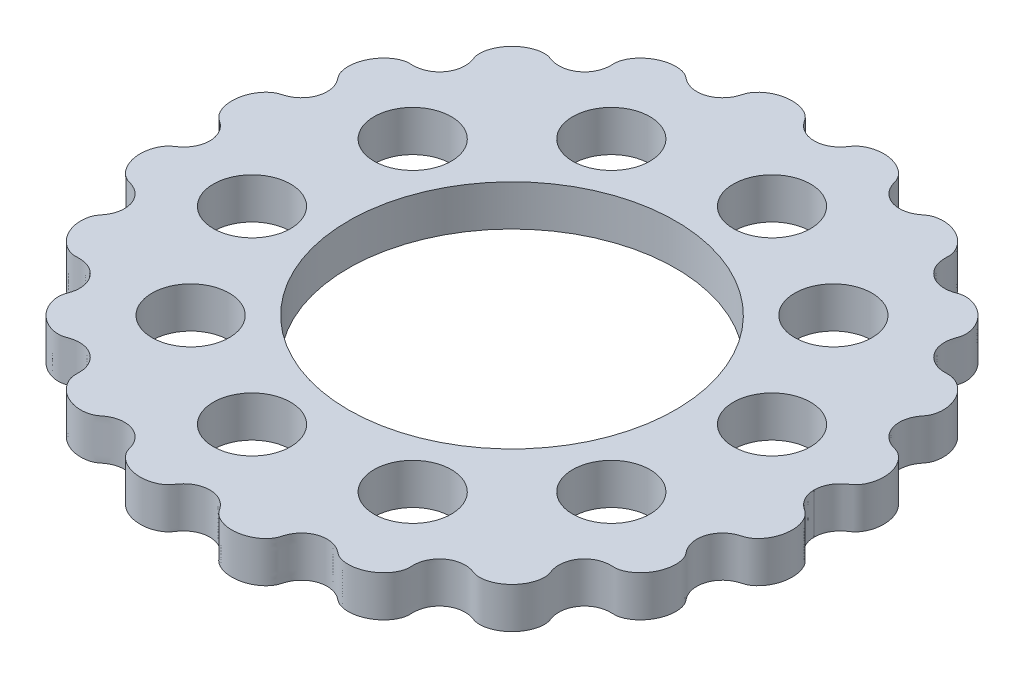
from build123d import *

# Parameters (mm, degrees)
SKETCH1_R           = 36
SKETCH1_R_2         = 8.5
BOSS_EXTRUDE1_DEPTH = 9


with BuildPart() as part:
    # Sketch1 → Boss-Extrude1 (new body)
    with BuildSketch(Plane(origin=(0, 0, 0), x_dir=(1, 0, 0), z_dir=(0, 1, 0))):
        with BuildLine():
            add(Edge.make_bspline(
                [(66.500001128, 0), (66.500001059, -0.306411594), (66.541874968, -0.881988953), (66.717851493, -1.709701791), (67.122305387, -2.644851491), (67.601319232, -3.385898949), (68.073478893, -3.930767458), (68.484626922, -4.318373679), (68.876385973, -4.631660736), (69.23366605, -4.885778545), (69.564274066, -5.103618626), (69.843214442, -5.321468249), (70.117872248, -5.581732182), (70.400827865, -5.901729423), (70.702289772, -6.323822122), (71.054596032, -6.952661705), (71.375662813, -7.747169256), (71.615376494, -8.685667315), (71.731212346, -9.758967782), (71.701410517, -10.823240749), (71.536133005, -11.860141317), (71.244225803, -12.853472484), (70.833511923, -13.788305153), (70.358839297, -14.565701482), (69.860707099, -15.191592971), (69.385303472, -15.666160963), (68.964677628, -16.012242354), (68.54812455, -16.287014566), (68.188697638, -16.47184613), (67.885284262, -16.589473761), (67.602667399, -16.678972646), (67.317739075, -16.760519914), (66.914744906, -16.885104227), (66.402737121, -17.079943872), (65.770956104, -17.391405147), (65.047003924, -17.880225418), (64.353873131, -18.53326648), (63.737773444, -19.372683578), (63.275037832, -20.335343335), (63.0008377, -21.369915642), (62.928927043, -22.453502643), (63.052813162, -23.427940228), (63.29775786, -24.251137277), (63.587039055, -24.893246727), (63.860894635, -25.371811065), (64.14516177, -25.790016356), (64.42550655, -26.153724672), (64.719695702, -26.532707758), (64.965405482, -26.968707858), (65.164480889, -27.455245241), (65.31533737, -27.986150481), (65.436916583, -28.660703569), (65.486679125, -29.479710927), (65.421096199, -30.426005629), (65.195898517, -31.477846243), (64.833514293, -32.483615902), (64.34589296, -33.427772819), (63.743613209, -34.295517302), (63.036397549, -35.071911937), (62.31941612, -35.667562121), (61.632614435, -36.102896741), (61.018606486, -36.397527132), (60.501368954, -36.585067293), (60.002736897, -36.705605448), (59.58278299, -36.754609085), (59.238659913, -36.755179392), (58.919479064, -36.74545807), (58.600187887, -36.737961797), (58.186622972, -36.744933287), (57.680555247, -36.788795106), (57.025772754, -36.90342477), (56.231100186, -37.148620439), (55.380154609, -37.568193838), (54.524775543, -38.212860553), (53.798856726, -39.016244646), (53.245744287, -39.931413305), (52.876403423, -40.932154503), (52.712876932, -41.903813394), (52.71112643, -42.801048319), (52.815319506, -43.527425087), (52.941387717, -44.033154822), (53.055590071, -44.395960767), (53.149312538, -44.668429528), (53.247939564, -44.939017738), (53.364965434, -45.291387687), (53.45219241, -45.737703326), (53.491958947, -46.257673261), (53.468644885, -46.845886586), (53.363394794, -47.556426715), (53.136734844, -48.374484468), (52.768362446, -49.246519445), (52.234936331, -50.143673448), (51.583820612, -50.970470144), (50.82500674, -51.71255133), (49.978560671, -52.346849839), (49.058219135, -52.860671903), (48.20083524, -53.193586938), (47.439728454, -53.383993294), (46.783575504, -53.471154388), (46.243400169, -53.490536958), (45.735563963, -53.453013122), (45.317452544, -53.369908656), (44.991727079, -53.265499676), (44.699608392, -53.161002685), (44.407046102, -53.057647907), (44.006263136, -52.932952751), (43.490986385, -52.811450458), (42.800133998, -52.714477579), (41.927158987, -52.709986791), (40.953037618, -52.867456762), (39.920202856, -53.248888969), (38.974122336, -53.827688375), (38.169054016, -54.570301655), (37.529920824, -55.442926734), (37.10189733, -56.344011558), (36.879347753, -57.124787428), (36.78026494, -57.75948784), (36.74543056, -58.228868163), (36.738116128, -58.595650919), (36.745630265, -58.954274122), (36.758794674, -59.304761395), (36.74528446, -59.700076552), (36.677901941, -60.135221885), (36.549281487, -60.614594775), (36.349127336, -61.129714817), (36.04054693, -61.740807428), (35.589726473, -62.423279244), (34.976854854, -63.134572488), (34.181164503, -63.833500064), (33.295605945, -64.424159898), (32.335438572, -64.896819576), (31.315952581, -65.240823473), (30.253281676, -65.444073244), (29.302808185, -65.486744282), (28.486094508, -65.414976344), (27.817189287, -65.273610717), (27.358637794, -65.126885219), (26.982811323, -64.964513335), (26.641526331, -64.7794663), (26.38252315, -64.604446296), (26.143451517, -64.417035727), (25.861696042, -64.202004354), (25.573543831, -63.995425393), (25.213648928, -63.766134462), (24.77357167, -63.531438351), (24.173339527, -63.273837977), (23.390590515, -63.045984286), (22.436442541, -62.9272463), (21.334482976, -63.005704166), (20.269322456, -63.297023223), (19.302800806, -63.777682853), (18.465112618, -64.415546123), (17.821174318, -65.123747711), (17.348875456, -65.844632989), (17.049246652, -66.473739286), (16.87955898, -66.936238427), (16.773116623, -67.27871396), (16.696957562, -67.537958364), (16.620563074, -67.797132006), (16.499910107, -68.130001521), (16.302573623, -68.520910326), (16.023587778, -68.951670557), (15.649895083, -69.406906758), (15.139193985, -69.909948046), (14.469235427, -70.425872158), (13.660692235, -70.898780651), (12.712675609, -71.294352148), (11.701994626, -71.570793248), (10.643277717, -71.717442021), (9.574432128, -71.722251809), (8.515173692, -71.581185143), (7.619740366, -71.330051456), (6.891782338, -71.021756352), (6.368073295, -70.723825795), (6.025748963, -70.488703324), (5.756441978, -70.272176079), (5.552614161, -70.086041745), (5.329274804, -69.853141567), (5.101427256, -69.562377498), (4.873847854, -69.214977549), (4.60464153, -68.839770094), (4.294594159, -68.458351882), (3.934688297, -68.081320026), (3.4174137, -67.628524208), (2.704193701, -67.152903461), (1.792081682, -66.743306019), (0.685094475, -66.494130595), (-0.466681251, -66.470382136), (-1.460634006, -66.655247728), (-2.272771141, -66.955831296), (-2.910711395, -67.297398997), (-3.378756398, -67.611091869), (-3.798269807, -67.955365828), (-4.170377952, -68.321327121), (-4.46025194, -68.657656792), (-4.682293422, -68.948557771), (-4.858086872, -69.197625908), (-4.995153001, -69.399303863), (-5.139637336, -69.607565652), (-5.30066338, -69.815692291), (-5.483879702, -70.017863174), (-5.688139816, -70.212714263), (-5.959120705, -70.439264474), (-6.305281109, -70.684848155), (-6.832662082, -70.993284834), (-7.564845294, -71.311344159), (-8.469002263, -71.572281829), (-9.541810964, -71.721249229), (-10.62436062, -71.719760269), (-11.695875611, -71.572466315), (-12.712675441, -71.294352571), (-13.660692303, -70.898780375), (-14.46923534, -70.425872341), (-15.139193993, -69.909947949), (-15.649895037, -69.40690682), (-16.023587763, -68.95167053), (-16.302573589, -68.520910355), (-16.499910085, -68.130001517), (-16.620563046, -67.797132021), (-16.696957538, -67.537958369), (-16.773116596, -67.278713971), (-16.879558957, -66.936238431), (-17.049246621, -66.473739301), (-17.348875437, -65.844632989), (-17.821174285, -65.123747732), (-18.465112607, -64.415546115), (-19.302800763, -63.777682889), (-20.269322463, -63.297023191), (-21.334482901, -63.005704246), (-22.436442607, -62.927246188), (-23.390590346, -63.045984495), (-24.17333974, -63.273837665), (-24.773571206, -63.531438965), (-25.213650233, -63.76613266), (-25.573539136, -63.995431782), (-25.861714806, -64.201978716), (-26.096423256, -64.381291369), (-26.283123055, -64.526166107), (-26.480463985, -64.670880418), (-26.693581001, -64.807563754), (-26.982772329, -64.964566552), (-27.358660612, -65.126854047), (-27.817177554, -65.273626716), (-28.486102111, -65.414965944), (-29.302803074, -65.48675124), (-30.253284842, -65.444068902), (-31.315950722, -65.240825994), (-32.335439647, -64.896818091), (-33.295605247, -64.424160835), (-34.181164906, -63.833499498), (-34.976854539, -63.134572903), (-35.589726623, -62.423279025), (-36.040546819, -61.740807566), (-36.349127362, -61.129714768), (-36.54928143, -60.61459484), (-36.67790194, -60.135221874), (-36.745284426, -59.700076587), (-36.758794659, -59.304761404), (-36.745630238, -58.954274147), (-36.738116109, -58.595650934), (-36.745430538, -58.228868183), (-36.78026492, -57.759487858), (-36.879347732, -57.124787447), (-37.10189731, -56.344011576), (-37.529920804, -55.442926753), (-38.169053997, -54.570301674), (-38.974122317, -53.827688394), (-39.920202837, -53.248888989), (-40.953037599, -52.867456782), (-41.927158969, -52.709986812), (-42.800133979, -52.7144776), (-43.490986366, -52.811450479), (-44.006263117, -52.932952773), (-44.407046083, -53.057647929), (-44.699608373, -53.161002708), (-44.99172706, -53.265499699), (-45.317452525, -53.369908679), (-45.735563943, -53.453013145), (-46.24340015, -53.49053698), (-46.783575485, -53.471154412), (-47.439728436, -53.383993317), (-48.200835218, -53.193586964), (-49.05821912, -52.860671924), (-49.978560646, -52.346849869), (-50.825006732, -51.712551347), (-51.58382058, -50.970470183), (-52.234936338, -50.143673452), (-52.768362387, -49.246519509), (-53.136734895, -48.374484434), (-53.363394674, -47.556426834), (-53.468645012, -46.845886486), (-53.491958675, -46.257673515), (-53.452192823, -45.737702973), (-53.364964725, -45.291388329), (-53.247940119, -44.939017259), (-53.149315767, -44.668426679), (-53.055570757, -44.395977907), (-52.969692355, -44.122896909), (-52.883657784, -43.80178229), (-52.788277591, -43.338670556), (-52.711291111, -42.706581427), (-52.712889666, -41.903802117), (-52.876396004, -40.932161097), (-53.24574868, -39.931409425), (-53.798854055, -39.01624703), (-54.524777209, -38.212859093), (-55.380153425, -37.568194906), (-56.231100936, -37.148619792), (-57.025772272, -36.903425216), (-57.680555542, -36.788794863), (-58.186622745, -36.744933508), (-58.600187986, -36.737961729), (-58.919479016, -36.745458132), (-59.238659916, -36.755179409), (-59.582782972, -36.754609121), (-60.002736891, -36.705605474), (-60.501368941, -36.585067325), (-61.018606477, -36.397527162), (-61.632614424, -36.102896772), (-62.319416111, -35.667562152), (-63.036397538, -35.071911969), (-63.7436132, -34.295517334), (-64.345892951, -33.427772851), (-64.833514284, -32.483615934), (-65.195898509, -31.477846275), (-65.421096192, -30.426005662), (-65.486679118, -29.47971096), (-65.436916577, -28.660703602), (-65.315337364, -27.986150513), (-65.164480883, -27.455245273), (-64.965405476, -26.968707891), (-64.719695696, -26.53270779), (-64.425506545, -26.153724704), (-64.145161765, -25.790016388), (-63.86089463, -25.371811097), (-63.58703905, -24.893246759), (-63.297757856, -24.251137308), (-63.052813158, -23.42794026), (-62.92892704, -22.453502674), (-63.000837697, -21.369915674), (-63.275037829, -20.335343367), (-63.737773443, -19.372683609), (-64.353873129, -18.533266513), (-65.047003923, -17.88022545), (-65.770956103, -17.39140518), (-66.40273712, -17.079943905), (-66.914744905, -16.885104261), (-67.317739074, -16.760519947), (-67.602667399, -16.67897268), (-67.885284262, -16.589473795), (-68.188697637, -16.471846164), (-68.548124549, -16.287014601), (-68.964677628, -16.012242388), (-69.385303472, -15.666160998), (-69.860707099, -15.191593006), (-70.358839297, -14.565701517), (-70.833511923, -13.788305189), (-71.244225804, -12.85347252), (-71.536133007, -11.860141352), (-71.701410519, -10.823240785), (-71.731212348, -9.758967818), (-71.615376497, -8.685667351), (-71.375662817, -7.747169291), (-71.054596036, -6.952661741), (-70.702289777, -6.323822157), (-70.40082787, -5.901729458), (-70.117872253, -5.581732217), (-69.843214447, -5.321468285), (-69.564274071, -5.103618659), (-69.233666057, -4.885778583), (-68.876385976, -4.631660764), (-68.484626931, -4.318373725), (-68.073478892, -3.930767473), (-67.601319247, -3.38589901), (-67.122305379, -2.644851485), (-66.717851516, -1.709701875), (-66.541874949, -0.881988899), (-66.500001067, -0.306411595), (-66.500001144, 0)],
                knots=[0.107227573, 0.107227573, 0.107227573, 0.107227573, 0.107227573, 0.110899605, 0.114125262, 0.117297955, 0.119365342, 0.12143273, 0.122745926, 0.124059122, 0.125372319, 0.126685515, 0.127489642, 0.128293769, 0.129902022, 0.131796763, 0.133691503, 0.136915486, 0.14013947, 0.143363023, 0.146586577, 0.149636972, 0.152687367, 0.155737512, 0.158787658, 0.160518035, 0.162248411, 0.16377611, 0.165303808, 0.166487656, 0.16707958, 0.167671505, 0.168855353, 0.170039201, 0.172133935, 0.174228668, 0.177277837, 0.180469506, 0.183482711, 0.186636923, 0.190006747, 0.193215352, 0.196415061, 0.198338344, 0.200261626, 0.201638223, 0.203014821, 0.204391418, 0.205768015, 0.20737848, 0.208988945, 0.210678965, 0.212368986, 0.215581346, 0.218793706, 0.222006092, 0.225218479, 0.228355258, 0.231492038, 0.234628768, 0.237765499, 0.239487542, 0.241209585, 0.242778062, 0.244346538, 0.245622308, 0.246260192, 0.246898077, 0.248173846, 0.249449616, 0.251214165, 0.252978714, 0.256127597, 0.259382101, 0.262517266, 0.265738303, 0.269026705, 0.272116988, 0.275225209, 0.2774808, 0.279736391, 0.280887314, 0.281462776, 0.282038237, 0.28318916, 0.284340084, 0.285905879, 0.287471675, 0.289425665, 0.291379655, 0.294497435, 0.297615215, 0.300732841, 0.303850467, 0.307074425, 0.310298382, 0.31337072, 0.316443057, 0.318059604, 0.319676151, 0.321292619, 0.322909086, 0.324148554, 0.324768288, 0.325388022, 0.32662749, 0.327866958, 0.329795802, 0.331724645, 0.334971979, 0.338289395, 0.341547885, 0.344835886, 0.34817973, 0.35133024, 0.354430803, 0.35672383, 0.357870343, 0.359016857, 0.360067543, 0.361118229, 0.362168914, 0.3632196, 0.364800497, 0.366381395, 0.368105721, 0.369830048, 0.372993142, 0.376156236, 0.379319389, 0.382482541, 0.385713434, 0.388944326, 0.392175014, 0.395405702, 0.397072955, 0.398740208, 0.400355996, 0.401163891, 0.401971785, 0.403387693, 0.404095647, 0.404803601, 0.40621951, 0.407635418, 0.409204663, 0.410773909, 0.414037141, 0.417372109, 0.420655125, 0.423928266, 0.427187498, 0.430226971, 0.433200462, 0.435339705, 0.437478948, 0.43855829, 0.43909796, 0.439637631, 0.440716972, 0.441796314, 0.443334185, 0.444872057, 0.446855976, 0.448839896, 0.451908577, 0.454977259, 0.45804593, 0.461114601, 0.464431853, 0.467749105, 0.470814309, 0.473879513, 0.475538589, 0.477197664, 0.478024147, 0.47885063, 0.479677113, 0.480503596, 0.481886651, 0.483269706, 0.48465276, 0.486035815, 0.487772004, 0.489508194, 0.492878492, 0.496270276, 0.499675403, 0.503014057, 0.506592321, 0.50830093, 0.51000954, 0.51167164, 0.513333741, 0.51479501, 0.51625628, 0.516986914, 0.517717549, 0.518448184, 0.519178819, 0.520023889, 0.52086896, 0.52171403, 0.522559101, 0.524253928, 0.525948755, 0.529023994, 0.532099233, 0.535492308, 0.538885383, 0.541954054, 0.545022725, 0.548091406, 0.551160088, 0.553144007, 0.555127927, 0.556665798, 0.55820367, 0.559283011, 0.560362353, 0.560902023, 0.561441694, 0.562521035, 0.564660278, 0.566799521, 0.569773013, 0.572812485, 0.576071718, 0.579344859, 0.582627875, 0.585962843, 0.589226075, 0.59079532, 0.592364566, 0.593780474, 0.595196382, 0.595904336, 0.59661229, 0.597320244, 0.598028198, 0.598836093, 0.599643987, 0.601259776, 0.602927029, 0.604594282, 0.60782497, 0.611055658, 0.61428655, 0.617517442, 0.620680595, 0.623843748, 0.627006842, 0.630169936, 0.631894262, 0.633618589, 0.635199486, 0.636780383, 0.637831069, 0.638881755, 0.639932441, 0.640983127, 0.64212964, 0.643276154, 0.645569181, 0.648669744, 0.651820253, 0.655164097, 0.658452098, 0.661710588, 0.665028004, 0.668275338, 0.670204182, 0.672133025, 0.673372493, 0.674611961, 0.675231696, 0.67585143, 0.677090898, 0.678707365, 0.680323832, 0.681940379, 0.683556927, 0.686629264, 0.689701601, 0.692925559, 0.696149516, 0.699267143, 0.702384769, 0.705502549, 0.708620329, 0.710574319, 0.712528308, 0.714094104, 0.7156599, 0.716810823, 0.717961746, 0.718537208, 0.719112669, 0.720263592, 0.721391388, 0.722519183, 0.724774775, 0.727882996, 0.730973278, 0.734261681, 0.737482718, 0.740617883, 0.743872386, 0.747021269, 0.748785818, 0.750550368, 0.751826137, 0.753101906, 0.753739791, 0.754377676, 0.755653445, 0.757221922, 0.758790398, 0.760512441, 0.762234484, 0.765371215, 0.768507946, 0.771644725, 0.774781505, 0.777993891, 0.781206278, 0.784418638, 0.787630998, 0.789321018, 0.791011039, 0.792621503, 0.794231968, 0.795608565, 0.796985163, 0.79836176, 0.799738358, 0.80166164, 0.803584922, 0.806784631, 0.809993236, 0.81336306, 0.816517272, 0.819530478, 0.822722147, 0.825771315, 0.827866049, 0.829960782, 0.831144631, 0.832328479, 0.832920403, 0.833512327, 0.834696176, 0.836223874, 0.837751572, 0.839481949, 0.841212326, 0.844262471, 0.847312617, 0.850363012, 0.853413407, 0.85663696, 0.859860514, 0.863084497, 0.866308481, 0.868203221, 0.870097961, 0.871706215, 0.872510342, 0.873314469, 0.874627665, 0.875940861, 0.877254057, 0.878567254, 0.880634641, 0.882702029, 0.885874721, 0.889100378, 0.892772411, 0.892772411, 0.892772411, 0.892772411, 0.892772411], degree=4))
            add(Edge.make_bspline(
                [(66.500001128, 0), (66.500001048, 0.306411644), (66.541874947, 0.881989055), (66.717851473, 1.709701945), (67.122305387, 2.644851692), (67.601319232, 3.38589915), (68.073478893, 3.930767659), (68.484626922, 4.318373879), (68.876385973, 4.631660937), (69.23366605, 4.885778745), (69.564274066, 5.103618826), (69.843214442, 5.32146845), (70.117872248, 5.581732383), (70.400827865, 5.901729623), (70.702289772, 6.323822322), (71.054596032, 6.952661906), (71.375662813, 7.747169456), (71.615376494, 8.685667516), (71.731212346, 9.758967983), (71.701410517, 10.82324095), (71.536133005, 11.860141517), (71.244225803, 12.853472685), (70.833511923, 13.788305354), (70.358839297, 14.565701682), (69.860707099, 15.191593171), (69.385303472, 15.666161164), (68.964677628, 16.012242554), (68.54812455, 16.287014767), (68.188697638, 16.471846331), (67.885284262, 16.589473962), (67.602667399, 16.678972847), (67.317739075, 16.760520114), (66.914744906, 16.885104428), (66.402737121, 17.079944072), (65.770956104, 17.391405347), (65.047003924, 17.880225618), (64.353873131, 18.533266681), (63.737773444, 19.372683778), (63.275037832, 20.335343536), (63.0008377, 21.369915843), (62.928927043, 22.453502843), (63.052813162, 23.427940429), (63.29775786, 24.251137477), (63.587039055, 24.893246928), (63.860894635, 25.371811266), (64.14516177, 25.790016557), (64.42550655, 26.153724872), (64.719695702, 26.532707958), (64.965405482, 26.968708059), (65.164480889, 27.455245441), (65.31533737, 27.986150681), (65.436916583, 28.66070377), (65.486679125, 29.479711128), (65.421096199, 30.426005829), (65.195898517, 31.477846443), (64.833514293, 32.483616102), (64.34589296, 33.427773019), (63.743613209, 34.295517502), (63.036397549, 35.071912137), (62.31941612, 35.667562321), (61.632614435, 36.102896941), (61.018606486, 36.397527333), (60.501368954, 36.585067493), (60.002736897, 36.705605648), (59.58278299, 36.754609285), (59.238659913, 36.755179592), (58.919479064, 36.745458271), (58.600187886, 36.737961997), (58.186622972, 36.744933488), (57.680555247, 36.788795306), (57.025772753, 36.90342497), (56.231100186, 37.148620639), (55.380154609, 37.568194039), (54.524775543, 38.212860754), (53.798856726, 39.016244846), (53.245744287, 39.931413505), (52.876403423, 40.932154703), (52.712876932, 41.903813594), (52.71112643, 42.80104852), (52.815319506, 43.527425287), (52.941387717, 44.033155022), (53.055590071, 44.395960967), (53.149312538, 44.668429729), (53.247939564, 44.939017938), (53.364965434, 45.291387887), (53.45219241, 45.737703526), (53.491958947, 46.257673461), (53.468644885, 46.845886786), (53.363394794, 47.556426915), (53.136734844, 48.374484668), (52.768362446, 49.246519645), (52.234936331, 50.143673648), (51.583820612, 50.970470345), (50.82500674, 51.71255153), (49.978560671, 52.34685004), (49.058219135, 52.860672104), (48.20083524, 53.193587139), (47.439728454, 53.383993495), (46.783575504, 53.471154589), (46.243400169, 53.490537158), (45.735563962, 53.453013323), (45.317452544, 53.369908857), (44.991727079, 53.265499877), (44.699608392, 53.161002886), (44.407046102, 53.057648107), (44.006263136, 52.932952951), (43.490986385, 52.811450658), (42.800133998, 52.714477779), (41.927158987, 52.709986991), (40.953037618, 52.867456962), (39.920202856, 53.248889169), (38.974122336, 53.827688575), (38.169054016, 54.570301855), (37.529920824, 55.442926934), (37.10189733, 56.344011758), (36.879347753, 57.124787628), (36.78026494, 57.75948804), (36.74543056, 58.228868364), (36.738116128, 58.595651119), (36.745630265, 58.954274323), (36.758794674, 59.304761595), (36.74528446, 59.700076752), (36.677901941, 60.135222085), (36.549281487, 60.614594976), (36.349127336, 61.129715017), (36.04054693, 61.740807628), (35.589726472, 62.423279444), (34.976854854, 63.134572689), (34.181164503, 63.833500264), (33.295605945, 64.424160099), (32.335438572, 64.896819776), (31.315952581, 65.240823674), (30.253281676, 65.444073444), (29.302808185, 65.486744482), (28.486094508, 65.414976544), (27.817189287, 65.273610917), (27.358637794, 65.12688542), (26.982811323, 64.964513535), (26.641526331, 64.7794665), (26.38252315, 64.604446497), (26.143451517, 64.417035928), (25.861696042, 64.202004554), (25.573543831, 63.995425594), (25.213648928, 63.766134662), (24.77357167, 63.531438552), (24.173339527, 63.273838177), (23.390590515, 63.045984486), (22.436442541, 62.927246501), (21.334482976, 63.005704366), (20.269322456, 63.297023423), (19.302800806, 63.777683053), (18.465112618, 64.415546323), (17.821174318, 65.123747912), (17.348875456, 65.844633189), (17.049246652, 66.473739486), (16.87955898, 66.936238627), (16.773116623, 67.278714161), (16.696957562, 67.537958564), (16.620563074, 67.797132207), (16.499910107, 68.130001722), (16.302573623, 68.520910526), (16.023587778, 68.951670757), (15.649895083, 69.406906958), (15.139193984, 69.909948246), (14.469235427, 70.425872358), (13.660692235, 70.898780851), (12.712675609, 71.294352349), (11.701994626, 71.570793448), (10.643277717, 71.717442222), (9.574432128, 71.72225201), (8.515173692, 71.581185343), (7.619740366, 71.330051656), (6.891782338, 71.021756552), (6.368073295, 70.723825995), (6.025748963, 70.488703524), (5.756441978, 70.27217628), (5.552614161, 70.086041945), (5.329274804, 69.853141768), (5.101427256, 69.562377698), (4.873847854, 69.21497775), (4.60464153, 68.839770294), (4.294594159, 68.458352082), (3.934688297, 68.081320226), (3.4174137, 67.628524408), (2.704193701, 67.152903662), (1.792081682, 66.74330622), (0.685094475, 66.494130795), (-0.466681251, 66.470382336), (-1.460634006, 66.655247928), (-2.272771141, 66.955831497), (-2.910711395, 67.297399197), (-3.378756398, 67.61109207), (-3.798269807, 67.955366028), (-4.170377952, 68.321327321), (-4.46025194, 68.657656993), (-4.682293422, 68.948557972), (-4.858086872, 69.197626109), (-4.995153001, 69.399304063), (-5.139637336, 69.607565852), (-5.30066338, 69.815692491), (-5.483879702, 70.017863374), (-5.688139816, 70.212714464), (-5.959120705, 70.439264675), (-6.305281109, 70.684848355), (-6.832662082, 70.993285034), (-7.564845294, 71.311344359), (-8.469002263, 71.57228203), (-9.541810964, 71.721249429), (-10.624360621, 71.71976047), (-11.695875611, 71.572466515), (-12.712675441, 71.294352771), (-13.660692303, 70.898780575), (-14.46923534, 70.425872542), (-15.139193993, 69.90994815), (-15.649895037, 69.40690702), (-16.023587763, 68.951670731), (-16.302573589, 68.520910555), (-16.499910085, 68.130001717), (-16.620563046, 67.797132221), (-16.696957538, 67.53795857), (-16.773116596, 67.278714171), (-16.879558957, 66.936238632), (-17.049246621, 66.473739501), (-17.348875437, 65.844633189), (-17.821174285, 65.123747932), (-18.465112607, 64.415546315), (-19.302800763, 63.777683089), (-20.269322463, 63.297023391), (-21.334482901, 63.005704446), (-22.436442607, 62.927246389), (-23.390590347, 63.045984695), (-24.17333974, 63.273837865), (-24.773571206, 63.531439165), (-25.213650233, 63.76613286), (-25.573539137, 63.995431983), (-25.861714806, 64.201978916), (-26.096423256, 64.38129157), (-26.283123055, 64.526166307), (-26.480463985, 64.670880618), (-26.693581001, 64.807563954), (-26.982772329, 64.964566752), (-27.358660612, 65.126854247), (-27.817177554, 65.273626916), (-28.486102111, 65.414966144), (-29.302803074, 65.486751441), (-30.253284842, 65.444069102), (-31.315950722, 65.240826194), (-32.335439647, 64.896818292), (-33.295605247, 64.424161035), (-34.181164906, 63.833499699), (-34.976854539, 63.134573104), (-35.589726623, 62.423279225), (-36.040546819, 61.740807767), (-36.349127362, 61.129714968), (-36.54928143, 60.614595041), (-36.67790194, 60.135222074), (-36.745284426, 59.700076787), (-36.758794659, 59.304761604), (-36.745630238, 58.954274348), (-36.738116109, 58.595651134), (-36.745430538, 58.228868384), (-36.78026492, 57.759488058), (-36.879347732, 57.124787647), (-37.10189731, 56.344011776), (-37.529920804, 55.442926953), (-38.169053997, 54.570301874), (-38.974122317, 53.827688595), (-39.920202837, 53.248889189), (-40.953037599, 52.867456983), (-41.927158969, 52.709987012), (-42.800133979, 52.7144778), (-43.490986366, 52.81145068), (-44.006263117, 52.932952973), (-44.407046083, 53.057648129), (-44.699608373, 53.161002908), (-44.99172706, 53.265499899), (-45.317452525, 53.369908879), (-45.735563943, 53.453013346), (-46.24340015, 53.490537181), (-46.783575485, 53.471154612), (-47.439728436, 53.383993517), (-48.200835218, 53.193587165), (-49.05821912, 52.860672125), (-49.978560646, 52.34685007), (-50.825006732, 51.712551548), (-51.58382058, 50.970470383), (-52.234936338, 50.143673653), (-52.768362387, 49.246519709), (-53.136734895, 48.374484635), (-53.363394674, 47.556427034), (-53.468645012, 46.845886686), (-53.491958675, 46.257673715), (-53.452192823, 45.737703173), (-53.364964725, 45.29138853), (-53.247940119, 44.93901746), (-53.149315767, 44.668426879), (-53.055570757, 44.395978107), (-52.969692355, 44.122897109), (-52.883657784, 43.801782491), (-52.788277591, 43.338670756), (-52.711291111, 42.706581628), (-52.712889666, 41.903802317), (-52.876396004, 40.932161297), (-53.24574868, 39.931409626), (-53.798854055, 39.016247231), (-54.524777209, 38.212859293), (-55.380153425, 37.568195106), (-56.231100936, 37.148619992), (-57.025772272, 36.903425416), (-57.680555542, 36.788795064), (-58.186622745, 36.744933709), (-58.600187986, 36.737961929), (-58.919479016, 36.745458333), (-59.238659916, 36.75517961), (-59.582782972, 36.754609322), (-60.002736891, 36.705605674), (-60.501368941, 36.585067525), (-61.018606477, 36.397527362), (-61.632614424, 36.102896972), (-62.319416111, 35.667562352), (-63.036397538, 35.071912169), (-63.7436132, 34.295517534), (-64.345892951, 33.427773051), (-64.833514284, 32.483616134), (-65.195898509, 31.477846476), (-65.421096192, 30.426005862), (-65.486679118, 29.47971116), (-65.436916577, 28.660703802), (-65.315337364, 27.986150714), (-65.164480883, 27.455245473), (-64.965405476, 26.968708091), (-64.719695696, 26.53270799), (-64.425506545, 26.153724904), (-64.145161765, 25.790016589), (-63.86089463, 25.371811297), (-63.58703905, 24.893246959), (-63.297757856, 24.251137509), (-63.052813158, 23.42794046), (-62.92892704, 22.453502875), (-63.000837697, 21.369915874), (-63.275037829, 20.335343567), (-63.737773443, 19.37268381), (-64.353873129, 18.533266713), (-65.047003923, 17.880225651), (-65.770956103, 17.39140538), (-66.40273712, 17.079944105), (-66.914744905, 16.885104461), (-67.317739074, 16.760520147), (-67.602667399, 16.67897288), (-67.885284262, 16.589473995), (-68.188697637, 16.471846364), (-68.548124549, 16.287014801), (-68.964677628, 16.012242588), (-69.385303472, 15.666161198), (-69.860707099, 15.191593206), (-70.358839297, 14.565701717), (-70.833511923, 13.788305389), (-71.244225804, 12.85347272), (-71.536133007, 11.860141553), (-71.701410519, 10.823240985), (-71.731212348, 9.758968018), (-71.615376497, 8.685667551), (-71.375662817, 7.747169491), (-71.054596036, 6.952661941), (-70.702289777, 6.323822357), (-70.40082787, 5.901729659), (-70.117872253, 5.581732417), (-69.843214447, 5.321468485), (-69.564274071, 5.103618859), (-69.233666057, 4.885778784), (-68.876385976, 4.631660964), (-68.484626931, 4.318373925), (-68.073478893, 3.930767674), (-67.601319247, 3.38589921), (-67.122305379, 2.644851686), (-66.717851496, 1.709702029), (-66.541874928, 0.881989001), (-66.500001056, 0.306411645), (-66.500001144, 0)],
                knots=[0.107227572, 0.107227572, 0.107227572, 0.107227572, 0.107227572, 0.110899605, 0.114125262, 0.117297955, 0.119365342, 0.12143273, 0.122745926, 0.124059122, 0.125372319, 0.126685515, 0.127489642, 0.128293769, 0.129902022, 0.131796763, 0.133691503, 0.136915486, 0.14013947, 0.143363023, 0.146586577, 0.149636972, 0.152687367, 0.155737512, 0.158787658, 0.160518035, 0.162248411, 0.16377611, 0.165303808, 0.166487656, 0.16707958, 0.167671505, 0.168855353, 0.170039201, 0.172133935, 0.174228668, 0.177277837, 0.180469506, 0.183482711, 0.186636923, 0.190006747, 0.193215352, 0.196415061, 0.198338344, 0.200261626, 0.201638223, 0.203014821, 0.204391418, 0.205768015, 0.20737848, 0.208988945, 0.210678965, 0.212368986, 0.215581346, 0.218793706, 0.222006092, 0.225218479, 0.228355258, 0.231492038, 0.234628768, 0.237765499, 0.239487542, 0.241209585, 0.242778062, 0.244346538, 0.245622308, 0.246260192, 0.246898077, 0.248173846, 0.249449616, 0.251214165, 0.252978714, 0.256127597, 0.259382101, 0.262517266, 0.265738303, 0.269026705, 0.272116988, 0.275225209, 0.2774808, 0.279736391, 0.280887314, 0.281462776, 0.282038237, 0.28318916, 0.284340084, 0.285905879, 0.287471675, 0.289425665, 0.291379655, 0.294497435, 0.297615215, 0.300732841, 0.303850467, 0.307074425, 0.310298382, 0.31337072, 0.316443057, 0.318059604, 0.319676151, 0.321292619, 0.322909086, 0.324148554, 0.324768288, 0.325388022, 0.32662749, 0.327866958, 0.329795802, 0.331724645, 0.334971979, 0.338289395, 0.341547885, 0.344835886, 0.34817973, 0.35133024, 0.354430803, 0.35672383, 0.357870343, 0.359016857, 0.360067543, 0.361118229, 0.362168914, 0.3632196, 0.364800497, 0.366381395, 0.368105721, 0.369830048, 0.372993142, 0.376156236, 0.379319389, 0.382482541, 0.385713434, 0.388944326, 0.392175014, 0.395405702, 0.397072955, 0.398740208, 0.400355996, 0.401163891, 0.401971785, 0.403387693, 0.404095647, 0.404803601, 0.40621951, 0.407635418, 0.409204663, 0.410773909, 0.414037141, 0.417372109, 0.420655125, 0.423928266, 0.427187498, 0.430226971, 0.433200462, 0.435339705, 0.437478948, 0.43855829, 0.43909796, 0.439637631, 0.440716972, 0.441796314, 0.443334185, 0.444872057, 0.446855976, 0.448839896, 0.451908577, 0.454977259, 0.45804593, 0.461114601, 0.464431853, 0.467749105, 0.470814309, 0.473879513, 0.475538589, 0.477197664, 0.478024147, 0.47885063, 0.479677113, 0.480503596, 0.481886651, 0.483269706, 0.48465276, 0.486035815, 0.487772004, 0.489508194, 0.492878492, 0.496270276, 0.499675403, 0.503014057, 0.506592321, 0.50830093, 0.51000954, 0.51167164, 0.513333741, 0.51479501, 0.51625628, 0.516986914, 0.517717549, 0.518448184, 0.519178819, 0.520023889, 0.52086896, 0.52171403, 0.522559101, 0.524253928, 0.525948755, 0.529023994, 0.532099233, 0.535492308, 0.538885383, 0.541954054, 0.545022725, 0.548091406, 0.551160088, 0.553144007, 0.555127927, 0.556665798, 0.55820367, 0.559283011, 0.560362353, 0.560902023, 0.561441694, 0.562521035, 0.564660278, 0.566799521, 0.569773013, 0.572812485, 0.576071718, 0.579344859, 0.582627875, 0.585962843, 0.589226075, 0.59079532, 0.592364566, 0.593780474, 0.595196382, 0.595904336, 0.59661229, 0.597320244, 0.598028198, 0.598836093, 0.599643987, 0.601259776, 0.602927029, 0.604594282, 0.60782497, 0.611055658, 0.61428655, 0.617517442, 0.620680595, 0.623843748, 0.627006842, 0.630169936, 0.631894262, 0.633618589, 0.635199486, 0.636780383, 0.637831069, 0.638881755, 0.639932441, 0.640983127, 0.64212964, 0.643276154, 0.645569181, 0.648669744, 0.651820253, 0.655164097, 0.658452098, 0.661710588, 0.665028004, 0.668275338, 0.670204182, 0.672133025, 0.673372493, 0.674611961, 0.675231696, 0.67585143, 0.677090898, 0.678707365, 0.680323832, 0.681940379, 0.683556927, 0.686629264, 0.689701601, 0.692925559, 0.696149516, 0.699267143, 0.702384769, 0.705502549, 0.708620329, 0.710574319, 0.712528308, 0.714094104, 0.7156599, 0.716810823, 0.717961746, 0.718537208, 0.719112669, 0.720263592, 0.721391388, 0.722519183, 0.724774775, 0.727882996, 0.730973278, 0.734261681, 0.737482718, 0.740617883, 0.743872386, 0.747021269, 0.748785818, 0.750550368, 0.751826137, 0.753101906, 0.753739791, 0.754377676, 0.755653445, 0.757221922, 0.758790398, 0.760512441, 0.762234484, 0.765371215, 0.768507946, 0.771644725, 0.774781505, 0.777993891, 0.781206278, 0.784418638, 0.787630998, 0.789321018, 0.791011039, 0.792621503, 0.794231968, 0.795608565, 0.796985163, 0.79836176, 0.799738358, 0.80166164, 0.803584922, 0.806784631, 0.809993236, 0.81336306, 0.816517272, 0.819530478, 0.822722147, 0.825771315, 0.827866049, 0.829960782, 0.831144631, 0.832328479, 0.832920403, 0.833512327, 0.834696176, 0.836223874, 0.837751572, 0.839481949, 0.841212326, 0.844262471, 0.847312617, 0.850363012, 0.853413407, 0.85663696, 0.859860514, 0.863084497, 0.866308481, 0.868203221, 0.870097961, 0.871706215, 0.872510342, 0.873314469, 0.874627665, 0.875940861, 0.877254057, 0.878567254, 0.880634641, 0.882702029, 0.885874721, 0.889100378, 0.892772411, 0.892772411, 0.892772411, 0.892772411, 0.892772411], degree=4))
        make_face()
        with Locations(Location((0, 0, 0), (0, 0, 270))):
            Circle(SKETCH1_R, mode=Mode.SUBTRACT)
        with Locations(Location((49.384417501, 7.821720275, 0), (0, 0, 270))):
            Circle(SKETCH1_R_2, mode=Mode.SUBTRACT)
        with Locations(Location((44.550324841, -22.699527672, 0), (0, 0, 270))):
            Circle(SKETCH1_R_2, mode=Mode.SUBTRACT)
        with Locations(Location((22.699522302, -44.550327578, 0), (0, 0, 270))):
            Circle(SKETCH1_R_2, mode=Mode.SUBTRACT)
        with Locations(Location((-7.821726229, -49.384416558, 0), (0, 0, 270))):
            Circle(SKETCH1_R_2, mode=Mode.SUBTRACT)
        with Locations(Location((-35.35534119, -35.355336928, 0), (0, 0, 270))):
            Circle(SKETCH1_R_2, mode=Mode.SUBTRACT)
        with Locations(Location((-49.384417501, -7.821720275, 0), (0, 0, 270))):
            Circle(SKETCH1_R_2, mode=Mode.SUBTRACT)
        with Locations(Location((-44.550324841, 22.699527672, 0), (0, 0, 270))):
            Circle(SKETCH1_R_2, mode=Mode.SUBTRACT)
        with Locations(Location((-22.699522302, 44.550327578, 0), (0, 0, 270))):
            Circle(SKETCH1_R_2, mode=Mode.SUBTRACT)
        with Locations(Location((7.821726229, 49.384416558, 0), (0, 0, 270))):
            Circle(SKETCH1_R_2, mode=Mode.SUBTRACT)
        with Locations(Location((35.35534119, 35.355336928, 0), (0, 0, 270))):
            Circle(SKETCH1_R_2, mode=Mode.SUBTRACT)
    extrude(amount=BOSS_EXTRUDE1_DEPTH)


solid = part.part
